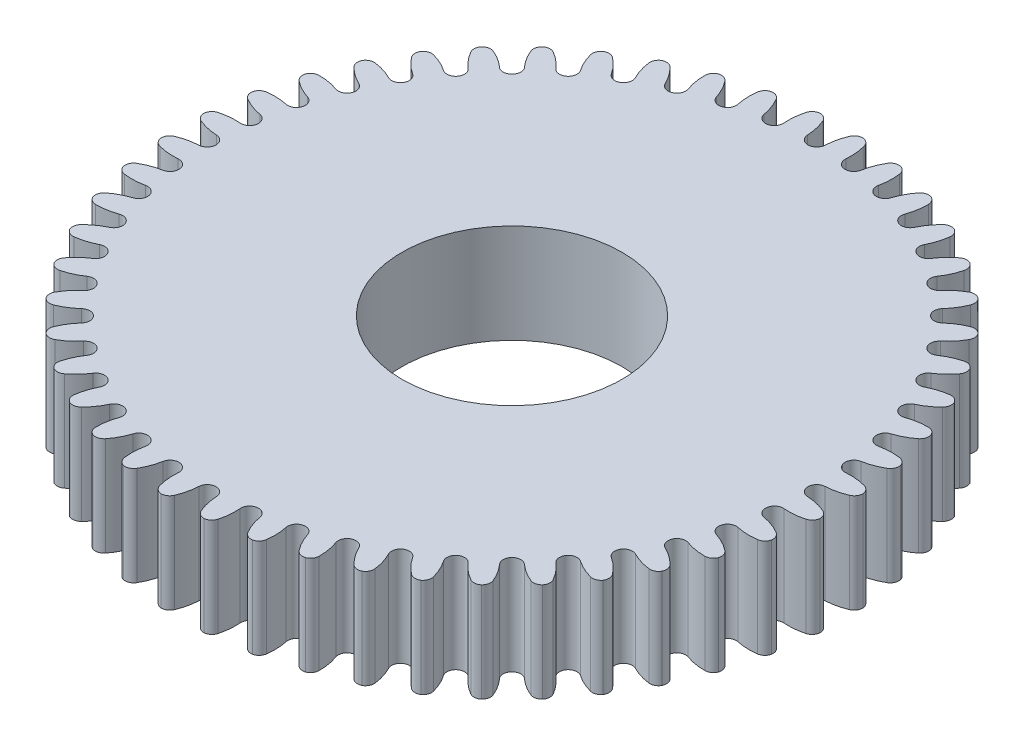
from build123d import *

# Parameters (mm, degrees)
SKETCH1_R           = 30
BOSS_EXTRUDE1_DEPTH = 9
CUT_EXTRUDE1_DEPTH  = 9
CIRPATTERN1_COUNT   = 48
SKETCH4_R           = 10
CUT_EXTRUDE3_DEPTH  = 9


with BuildPart() as part:
    # Sketch1 → Boss-Extrude1 (new body)
    with BuildSketch(Plane(origin=(0, 0, 0), x_dir=(1, 0, 0), z_dir=(0, 1, 0))):
        Circle(SKETCH1_R)
    extrude(amount=BOSS_EXTRUDE1_DEPTH)

    # Sketch3 → Cut-Extrude1 (cut)
    with BuildSketch(Plane.XZ):
        with BuildLine():
            ThreePointArc((1.210058579, -29.448752383), (0.924049006, -28.566958769), (0.799158179, -27.648392639))
            ThreePointArc((0.799158179, -27.648392639), (0, -26.8850833), (-0.799158179, -27.648392639))
            ThreePointArc((-0.799158179, -27.648392639), (-0.924049006, -28.566958769), (-1.210058579, -29.448752383))
            ThreePointArc((-1.210058579, -29.448752383), (-1.527440871, -29.816850971), (-1.999316497, -29.933304755))
            ThreePointArc((-1.999316497, -29.933304755), (1.3e-08, -30), (1.999316523, -29.933304753))
            ThreePointArc((1.999316523, -29.933304753), (1.527440882, -29.816850978), (1.210058579, -29.448752383))
        make_face()
    cut_extrude1 = extrude(amount=-CUT_EXTRUDE1_DEPTH, mode=Mode.SUBTRACT)

    # CirPattern1: Cut-Extrude1 ×48 about axis
    cirpattern1_axis = Axis((0, 0, 0), (0, 1, 0))
    for i in range(1, CIRPATTERN1_COUNT):
        add(cut_extrude1.rotate(cirpattern1_axis, i * 360 / CIRPATTERN1_COUNT), mode=Mode.SUBTRACT)

    # Sketch4 → Cut-Extrude3 (cut)
    with BuildSketch(Plane.XZ):
        Circle(SKETCH4_R)
    extrude(amount=-CUT_EXTRUDE3_DEPTH, mode=Mode.SUBTRACT)


solid = part.part
